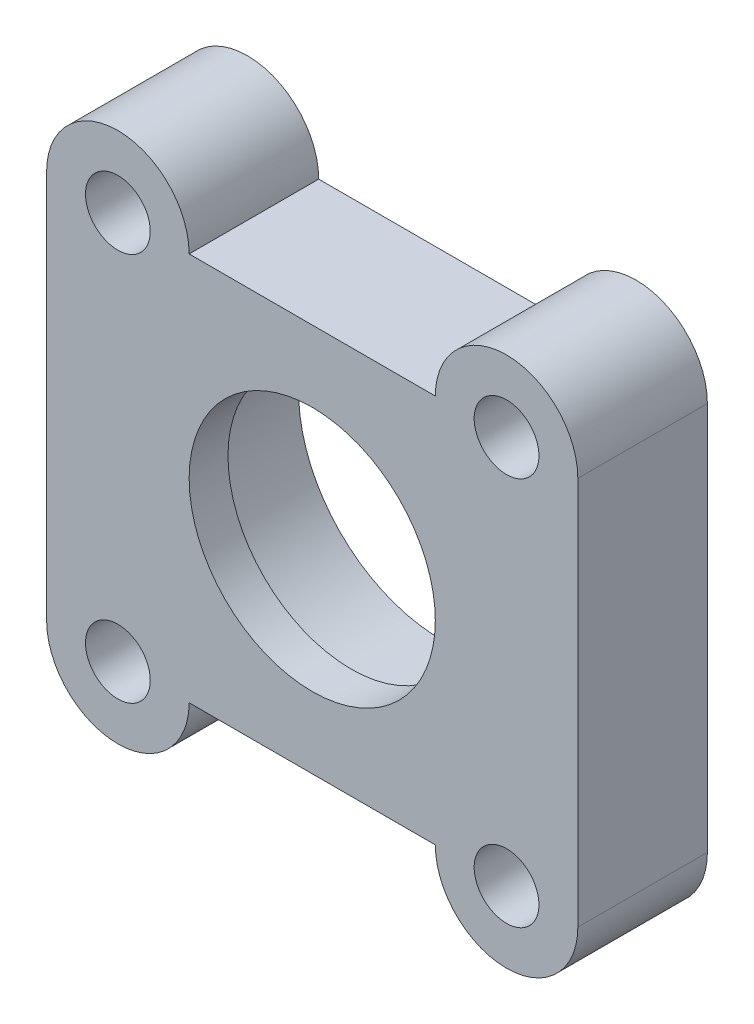
from build123d import *

# Parameters (mm, degrees)
CROQUIS1_R              = 11.05
CROQUIS1_R_2            = 2.5
SALIENTE_EXTRUIR1_DEPTH = 10
CROQUIS2_R              = 13
CROQUIS2_R_2            = 9.5
SALIENTE_EXTRUIR2_DEPTH = 3


with BuildPart() as part:
    # Croquis1 → Saliente-Extruir1 (new body)
    with BuildSketch(Plane.XY):
        with BuildLine():
            Line((-57.878391193, 30.074329664), (-57.878391193, 0.074329664))
            ThreePointArc((-57.878391193, 0.074329664), (-52.378391193, -5.425670336), (-46.878391193, 0.074329664))
            Line((-46.878391193, 0.074329664), (-27.878391193, 0.074329664))
            ThreePointArc((-27.878391193, 0.074329664), (-22.378391193, -5.425670336), (-16.878391193, 0.074329664))
            Line((-16.878391193, 0.074329664), (-16.878391193, 30.074329664))
            ThreePointArc((-16.878391193, 30.074329664), (-22.378391193, 35.574329664), (-27.878391193, 30.074329664))
            Line((-27.878391193, 30.074329664), (-46.878391193, 30.074329664))
            ThreePointArc((-46.878391193, 30.074329664), (-52.378391193, 35.574329664), (-57.878391193, 30.074329664))
        make_face()
        with Locations((-37.378391193, 15.074329664)):
            Circle(CROQUIS1_R, mode=Mode.SUBTRACT)
        with Locations((-22.378391193, 0.074329664)):
            Circle(CROQUIS1_R_2, mode=Mode.SUBTRACT)
        with Locations((-52.378391193, 0.074329664)):
            Circle(CROQUIS1_R_2, mode=Mode.SUBTRACT)
        with Locations((-52.378391193, 30.074329664)):
            Circle(CROQUIS1_R_2, mode=Mode.SUBTRACT)
        with Locations((-22.378391193, 30.074329664)):
            Circle(CROQUIS1_R_2, mode=Mode.SUBTRACT)
    extrude(amount=SALIENTE_EXTRUIR1_DEPTH)

    # Croquis2 → Saliente-Extruir2 (add)
    with BuildSketch(Plane.XY.offset(10)):
        with Locations((-37.378391193, 15.074329664)):
            Circle(CROQUIS2_R)
        with Locations((-37.378391193, 15.074329664)):
            Circle(CROQUIS2_R_2, mode=Mode.SUBTRACT)
    extrude(amount=-SALIENTE_EXTRUIR2_DEPTH)


solid = part.part
